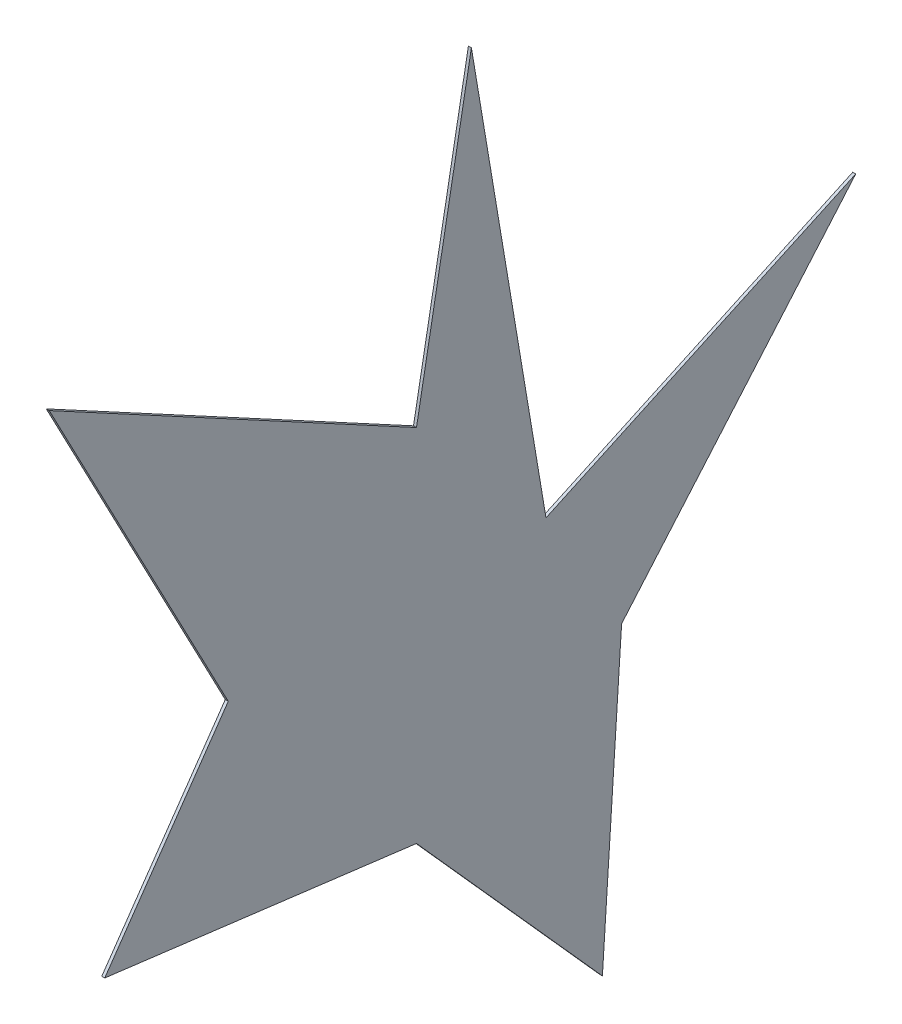
from build123d import *

# Parameters (mm, degrees)
BOSS_EXTRUDE1_DEPTH = 10


with BuildPart() as part:
    # Sketch1 → Boss-Extrude1 (new body)
    with BuildSketch(Plane(origin=(0, 0, 0), x_dir=(0, 0, -1), z_dir=(1, 0, 0))):
        Polygon((-3954.918303952, -2387.627964502), (-3770.33840501, -1374.179840119), (-3519.588353616, -2868.232229674), (-2478.279112411, -2387.627964502), (-3265.355662619, -3303.56218001), (-3329.937731412, -4296.69955023), (-3954.918303952, -3598.61140715), (-5002.942074311, -3466.215380014), (-4587.699989203, -2868.232229674), (-5189.500112548, -1720.995022313), align=None)
    extrude(amount=BOSS_EXTRUDE1_DEPTH)


solid = part.part
